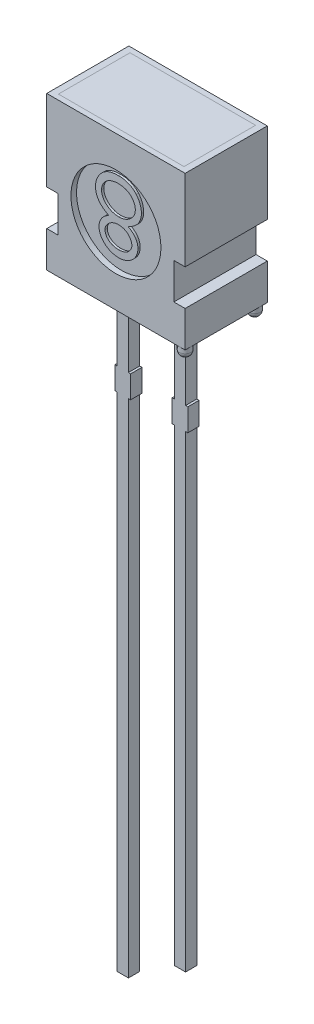
from build123d import *

# Parameters (mm, degrees)
EXTRUDE1_DEPTH     = 1.825
EXTRUDE2_DEPTH     = 0.25
SKETCH2_W          = 5.58
SKETCH2_H          = 3.18
CUT_EXTRUDE1_DEPTH = 6.8
CUT_EXTRUDE1_DRAFT = -4
SKETCH2_5_W        = 5.58
SKETCH2_5_H        = 3.18
EXTRUDE4_DEPTH     = 6.8
EXTRUDE4_DRAFT     = -4
SKETCH3_R          = 0.25
EXTRUDE5_DEPTH     = 0.5
EXTRUDE5_2_DEPTH   = 0.5
EXTRUDE5_3_DEPTH   = 0.5
FILLET1_R          = 0.25
FILLET2_R          = 0.25
FILLET3_R          = 0.25
SKETCH4_R          = 2
CUT_EXTRUDE2_DEPTH = 0.25
EXTRUDE6_DEPTH     = 0.1
SKETCH6_W          = 0.025316456
SKETCH6_H          = 0.026582278
CUT_EXTRUDE3_DEPTH = 0.01


with BuildPart() as part:
    # Sketch1 → Extrude1 (new body, symmetric)
    with BuildSketch(Plane.XY):
        Polygon((3.075, 3.4), (-3.075, 3.4), (-3.075, -0.2), (-2.575, -0.2), (-2.575, -1.8), (-3.075, -1.8), (-3.075, -3.4), (-1.52, -3.4), (-1.02, -3.4), (1.02, -3.4), (1.52, -3.4), (3.075, -3.4), (3.075, -1.8), (2.575, -1.8), (2.575, -0.2), (3.075, -0.2), align=None)
    extrude(amount=EXTRUDE1_DEPTH, both=True)

    # Sketch1_3 → Extrude2 (add, symmetric)
    with BuildSketch(Plane.XY):
        Polygon((-1.02, -3.4), (-1.52, -3.4), (-1.52, -7.1), (-1.62, -7.1), (-1.62, -8.1), (-1.52, -8.1), (-1.52, -30.4), (-1.02, -30.4), (-1.02, -8.1), (-0.92, -8.1), (-0.92, -7.1), (-1.02, -7.1), align=None)
        Polygon((1.52, -7.1), (1.52, -3.4), (1.02, -3.4), (1.02, -7.1), (0.92, -7.1), (0.92, -8.1), (1.02, -8.1), (1.02, -28.9), (1.52, -28.9), (1.52, -8.1), (1.62, -8.1), (1.62, -7.1), align=None)
    extrude(amount=EXTRUDE2_DEPTH, both=True)


with BuildPart() as cut_extrude1_tool:
    # Sketch2 → Cut-Extrude1 (with draft: the straight prism first)
    with BuildSketch(Plane(origin=(0, 3.4, 0), x_dir=(-1, 0, 0), z_dir=(0, 1, 0))):
        Rectangle(SKETCH2_W, SKETCH2_H)
    extrude(amount=-CUT_EXTRUDE1_DEPTH)
    # Cut-Extrude1: the draft: its side faces are tilted about the plane it starts from
    cut_extrude1_sides = [cut_extrude1_tool.faces().sort_by_distance(p)[0] for p in [
        (-2.79, 0, 0),
        (0, 0, 1.59),
        (2.79, 0, 0),
        (0, 0, -1.59),
    ]]
    draft(cut_extrude1_sides, Plane(origin=(0, 3.4, 0), x_dir=(-1, 0, 0), z_dir=(0, 1, 0)), CUT_EXTRUDE1_DRAFT)


with BuildPart() as part_1:
    add(part.part)

    # Cut-Extrude1: cut by cut_extrude1_tool
    add(cut_extrude1_tool.part, mode=Mode.SUBTRACT)

    # Sketch4 → Cut-Extrude2 (cut)
    with BuildSketch(Plane.XY.offset(1.825)):
        Circle(SKETCH4_R)
    extrude(amount=-CUT_EXTRUDE2_DEPTH, mode=Mode.SUBTRACT)

    # Sketch6 → Cut-Extrude3 (cut)
    with BuildSketch(Plane.XZ.offset(3.4)):
        Polygon((-0.609025376, -1.458987967), (-0.632482654, -1.533671511), (-0.657225534, -1.533671511), (-0.673641673, -1.483335277), (-0.689167781, -1.533671511), (-0.714899584, -1.533671511), (-0.7381393, -1.458987967), (-0.712961293, -1.458987967), (-0.699966831, -1.510471353), (-0.683550692, -1.458987967), (-0.662051483, -1.458987967), (-0.645734236, -1.510471353), (-0.632917781, -1.458987967), align=None)
        Polygon((-0.47484816, -1.458987967), (-0.498305439, -1.533671511), (-0.523048319, -1.533671511), (-0.539464458, -1.483335277), (-0.554990565, -1.533671511), (-0.580722369, -1.533671511), (-0.603962084, -1.458987967), (-0.578784078, -1.458987967), (-0.565789616, -1.510471353), (-0.549373477, -1.458987967), (-0.527874268, -1.458987967), (-0.511557021, -1.510471353), (-0.498740565, -1.458987967), align=None)
        Polygon((-0.340670945, -1.458987967), (-0.364128224, -1.533671511), (-0.388871103, -1.533671511), (-0.405287243, -1.483335277), (-0.42081335, -1.533671511), (-0.446545154, -1.533671511), (-0.469784869, -1.458987967), (-0.444606863, -1.458987967), (-0.431612401, -1.510471353), (-0.415196262, -1.458987967), (-0.393697053, -1.458987967), (-0.377379806, -1.510471353), (-0.36456335, -1.458987967), align=None)
        with Locations((-0.312822844, -1.520380372)):
            Rectangle(SKETCH6_W, SKETCH6_H)
        with BuildLine():
            add(Edge.make_bspline(
                [(-0.196367148, -1.502500625), (-0.196403637, -1.503722767), (-0.196475289, -1.506122645), (-0.197085006, -1.509630223), (-0.198078493, -1.512954928), (-0.19945261, -1.516117589), (-0.201241413, -1.519096207), (-0.203451003, -1.521876484), (-0.206015416, -1.524511284), (-0.208981626, -1.526917415), (-0.212261736, -1.529121791), (-0.215859311, -1.53101879), (-0.219738016, -1.532615273), (-0.223886602, -1.533953825), (-0.228333041, -1.534942405), (-0.23305057, -1.535666351), (-0.238043989, -1.53613968), (-0.241467567, -1.536181647), (-0.243222369, -1.536203157)],
                knots=[0, 0, 0, 0, 0.907352243, 1.781736951, 2.63548328, 3.47985091, 4.336556021, 5.208523475, 6.112432747, 7.062451073, 8.040435374, 9.043840564, 10.077958095, 11.152835584, 12.277940427, 13.457536469, 14.696825396, 16, 16, 16, 16], degree=3))
            add(Edge.make_bspline(
                [(-0.243222369, -1.536203157), (-0.245240625, -1.536179085), (-0.249149807, -1.536132461), (-0.254813332, -1.535703861), (-0.260081369, -1.535057722), (-0.264977084, -1.53409118), (-0.269581683, -1.532890415), (-0.274014951, -1.531599124), (-0.278296263, -1.530134708), (-0.281069352, -1.52903455), (-0.282443097, -1.528489549)],
                knots=[0, 0, 0, 0, 1.203215828, 2.33052265, 3.384689099, 4.366106119, 5.303329643, 6.221311756, 7.118865988, 8, 8, 8, 8], degree=3))
            Line((-0.282443097, -1.528489549), (-0.282443097, -1.504557587))
            Line((-0.282443097, -1.504557587), (-0.279594996, -1.504557587))
            add(Edge.make_bspline(
                [(-0.279594996, -1.504557587), (-0.278229682, -1.505639042), (-0.275507069, -1.507795603), (-0.271073836, -1.510558208), (-0.26642619, -1.512960371), (-0.261580719, -1.514934373), (-0.256683875, -1.516520697), (-0.251808497, -1.517614225), (-0.24704291, -1.518361574), (-0.24388434, -1.51844208), (-0.242332338, -1.518481638)],
                knots=[0, 0, 0, 0, 1.030622468, 2.055194264, 3.087043286, 4.125157485, 5.149848264, 6.130935704, 7.081611712, 8, 8, 8, 8], degree=3))
            add(Edge.make_bspline(
                [(-0.242332338, -1.518481638), (-0.241903561, -1.518480714), (-0.240985585, -1.518478737), (-0.239524058, -1.51835101), (-0.237872247, -1.518255433), (-0.236099738, -1.518048249), (-0.234303012, -1.517826388), (-0.232640611, -1.517451463), (-0.231131016, -1.517086596), (-0.230224495, -1.516718599), (-0.229792781, -1.516543347)],
                knots=[0, 0, 0, 0, 0.806402781, 1.726445712, 2.758724871, 3.919014682, 5.083870887, 6.16165551, 7.124521387, 8, 8, 8, 8], degree=3))
            add(Edge.make_bspline(
                [(-0.229792781, -1.516543347), (-0.229313218, -1.516315205), (-0.228370774, -1.515866858), (-0.227077175, -1.515056539), (-0.225909495, -1.514173074), (-0.224852123, -1.513208143), (-0.223977843, -1.512042393), (-0.223353976, -1.510633721), (-0.223009083, -1.508984703), (-0.222970059, -1.5078095), (-0.222949426, -1.507188125)],
                knots=[0, 0, 0, 0, 1.024747072, 2.013846092, 2.940605744, 3.850156746, 4.769278501, 5.73222711, 6.800942666, 8, 8, 8, 8], degree=3))
            add(Edge.make_bspline(
                [(-0.222949426, -1.507188125), (-0.222981271, -1.506642488), (-0.223043887, -1.505569604), (-0.22362108, -1.50403449), (-0.224530518, -1.502625321), (-0.225812108, -1.501356547), (-0.227405284, -1.500207013), (-0.229347667, -1.499224708), (-0.231597788, -1.49835152), (-0.233241859, -1.497933542), (-0.234104489, -1.497714233)],
                knots=[0, 0, 0, 0, 0.82557554, 1.623324704, 2.456147571, 3.35491006, 4.343819762, 5.427079081, 6.650009487, 8, 8, 8, 8], degree=3))
            add(Edge.make_bspline(
                [(-0.234104489, -1.497714233), (-0.236073116, -1.497265993), (-0.240112126, -1.496346342), (-0.24626195, -1.495207588), (-0.252390301, -1.493932728), (-0.256343067, -1.492726085), (-0.258273793, -1.492136701)],
                knots=[0, 0, 0, 0, 0.976100998, 2.002656142, 3.024398856, 4, 4, 4, 4], degree=3))
            add(Edge.make_bspline(
                [(-0.258273793, -1.492136701), (-0.259312311, -1.491783711), (-0.261333884, -1.491096583), (-0.264225396, -1.489934923), (-0.266886623, -1.488665094), (-0.269326337, -1.487309539), (-0.271527026, -1.485836999), (-0.273521293, -1.484295621), (-0.27528441, -1.482655581), (-0.276831215, -1.480915815), (-0.278156117, -1.479065112), (-0.279308502, -1.477119915), (-0.280291122, -1.475064495), (-0.28106916, -1.472894272), (-0.2816938, -1.470620617), (-0.282112782, -1.468242905), (-0.282411799, -1.465759776), (-0.282432522, -1.464065391), (-0.282443097, -1.463200784)],
                knots=[0, 0, 0, 0, 1.287047841, 2.5053592, 3.654260482, 4.74538952, 5.777514103, 6.75871007, 7.700244599, 8.599107454, 9.48590269, 10.366941872, 11.24940663, 12.154970331, 13.068988358, 14.012872203, 14.986013017, 16, 16, 16, 16], degree=3))
            add(Edge.make_bspline(
                [(-0.282443097, -1.463200784), (-0.282405795, -1.462044639), (-0.282332386, -1.459769367), (-0.281730957, -1.456440322), (-0.280704367, -1.453291586), (-0.279318304, -1.450288123), (-0.277489676, -1.447475037), (-0.275304881, -1.444796489), (-0.272680833, -1.442324898), (-0.269703712, -1.440024564), (-0.266416328, -1.437945165), (-0.262877344, -1.436114609), (-0.259108055, -1.434577958), (-0.255122508, -1.433304064), (-0.25090404, -1.432349393), (-0.246466807, -1.431630461), (-0.241793018, -1.431217279), (-0.238601597, -1.431166029), (-0.236972369, -1.431139866)],
                knots=[0, 0, 0, 0, 0.894990994, 1.761326291, 2.609044902, 3.454222546, 4.315366365, 5.200560057, 6.125081389, 7.100429509, 8.110379559, 9.133447974, 10.182136699, 11.259192205, 12.370181258, 13.528580438, 14.738335141, 16, 16, 16, 16], degree=3))
            add(Edge.make_bspline(
                [(-0.236972369, -1.431139866), (-0.235303675, -1.431162019), (-0.231969117, -1.431206287), (-0.226987777, -1.431584844), (-0.222033349, -1.432137155), (-0.217170924, -1.432986396), (-0.212478761, -1.433954628), (-0.208059647, -1.435053901), (-0.203980094, -1.436291407), (-0.201406441, -1.437245809), (-0.200164616, -1.437706322)],
                knots=[0, 0, 0, 0, 1.065407564, 2.129008667, 3.188544425, 4.247469455, 5.279542408, 6.247502114, 7.154394069, 8, 8, 8, 8], degree=3))
            Line((-0.200164616, -1.437706322), (-0.200164616, -1.46025379))
            Line((-0.200164616, -1.46025379), (-0.202992939, -1.46025379))
            add(Edge.make_bspline(
                [(-0.202992939, -1.46025379), (-0.204066442, -1.459454502), (-0.20625722, -1.457823337), (-0.209906824, -1.455721601), (-0.213874444, -1.45378151), (-0.21815607, -1.452089853), (-0.222615851, -1.450631846), (-0.227198609, -1.449612288), (-0.231824825, -1.44897058), (-0.234926529, -1.448897791), (-0.236477907, -1.448861385)],
                knots=[0, 0, 0, 0, 0.892265782, 1.820912499, 2.804518821, 3.836954028, 4.889985052, 5.931488012, 6.965393252, 8, 8, 8, 8], degree=3))
            add(Edge.make_bspline(
                [(-0.236477907, -1.448861385), (-0.237573512, -1.448883287), (-0.239771156, -1.448927221), (-0.243040347, -1.449312107), (-0.246280825, -1.44995096), (-0.248315507, -1.450767011), (-0.24933392, -1.451175467)],
                knots=[0, 0, 0, 0, 0.999122297, 2.004111588, 3.001004448, 4, 4, 4, 4], degree=3))
            add(Edge.make_bspline(
                [(-0.24933392, -1.451175467), (-0.249767649, -1.451376646), (-0.250634819, -1.45177887), (-0.251842361, -1.452558495), (-0.252963333, -1.453474839), (-0.253958916, -1.454527596), (-0.25480335, -1.45569595), (-0.255422376, -1.456963532), (-0.255796869, -1.458327414), (-0.255839216, -1.459262513), (-0.255860819, -1.459739549)],
                knots=[0, 0, 0, 0, 1.004925302, 2.009180302, 3.014392739, 4.04465309, 5.049195417, 6.035570224, 6.99785458, 8, 8, 8, 8], degree=3))
            add(Edge.make_bspline(
                [(-0.255860819, -1.459739549), (-0.25582638, -1.460377715), (-0.255760572, -1.46159719), (-0.255153988, -1.463312986), (-0.254169155, -1.46479142), (-0.25300855, -1.46578634), (-0.25189142, -1.466483778), (-0.250855761, -1.466994289), (-0.249646533, -1.467477648), (-0.248275286, -1.467975116), (-0.246738959, -1.468466304), (-0.245030402, -1.46894185), (-0.243147685, -1.469391146), (-0.24183181, -1.469677337), (-0.241145629, -1.469826575)],
                knots=[0, 0, 0, 0, 1.173816843, 2.243057204, 3.312297565, 4.415174738, 5.03266065, 5.73970059, 6.541434878, 7.433956553, 8.430083051, 9.515931566, 10.70464786, 12, 12, 12, 12], degree=3))
            add(Edge.make_bspline(
                [(-0.241145629, -1.469826575), (-0.239312706, -1.470202019), (-0.23571774, -1.47093839), (-0.230318516, -1.472050756), (-0.224813528, -1.473316115), (-0.221142376, -1.474468111), (-0.219231072, -1.475067872)],
                knots=[0, 0, 0, 0, 0.995749986, 1.952994291, 2.934271555, 4, 4, 4, 4], degree=3))
            add(Edge.make_bspline(
                [(-0.219231072, -1.475067872), (-0.218284583, -1.475387231), (-0.216433099, -1.476011949), (-0.213791552, -1.477096633), (-0.211342499, -1.478278722), (-0.209064228, -1.479501208), (-0.207002147, -1.480864425), (-0.205108923, -1.482279072), (-0.203425905, -1.483807181), (-0.201927955, -1.485420039), (-0.200609554, -1.487130471), (-0.19947459, -1.488968574), (-0.198511444, -1.490923103), (-0.197703313, -1.492996175), (-0.197125297, -1.495203243), (-0.196691239, -1.497529543), (-0.196400417, -1.499974859), (-0.196378361, -1.501649305), (-0.196367148, -1.502500625)],
                knots=[0, 0, 0, 0, 1.237386967, 2.420528625, 3.534815053, 4.605870898, 5.620827102, 6.594482803, 7.531295079, 8.432978826, 9.318460435, 10.202471551, 11.10474705, 12.014900263, 12.954095338, 13.926516828, 14.945802342, 16, 16, 16, 16], degree=3))
        make_face()
        with BuildLine():
            Line((-0.103962084, -1.533671511), (-0.128012717, -1.533671511))
            Line((-0.128012717, -1.533671511), (-0.128012717, -1.525839233))
            add(Edge.make_bspline(
                [(-0.128012717, -1.525839233), (-0.129105973, -1.5266479), (-0.131213753, -1.528206999), (-0.134387492, -1.530285763), (-0.137416213, -1.532068925), (-0.140337814, -1.533611078), (-0.143353169, -1.534801925), (-0.146580672, -1.535623781), (-0.150082936, -1.536124901), (-0.15250991, -1.536176492), (-0.1537643, -1.536203157)],
                knots=[0, 0, 0, 0, 1.150906677, 2.218931226, 3.20955724, 4.125565256, 5.012676028, 5.946647191, 6.938718366, 8, 8, 8, 8], degree=3))
            add(Edge.make_bspline(
                [(-0.1537643, -1.536203157), (-0.154780645, -1.536180428), (-0.156759763, -1.536136168), (-0.159637092, -1.53579143), (-0.162344404, -1.535253284), (-0.164860554, -1.534447428), (-0.167225899, -1.533473311), (-0.169377418, -1.532214224), (-0.171365106, -1.530754887), (-0.173168484, -1.529077951), (-0.174759103, -1.527156989), (-0.176146154, -1.525034238), (-0.177321966, -1.5226996), (-0.178263604, -1.520148233), (-0.179018537, -1.517389789), (-0.179542515, -1.514410582), (-0.179863095, -1.511223443), (-0.179895036, -1.509028314), (-0.179911451, -1.507900151)],
                knots=[0, 0, 0, 0, 1.108935798, 2.159418225, 3.158520219, 4.116592843, 5.038730546, 5.944611115, 6.829677354, 7.725673622, 8.624842385, 9.544872214, 10.487719724, 11.471363217, 12.50822837, 13.604887271, 14.769056852, 16, 16, 16, 16], degree=3))
            Line((-0.179911451, -1.507900151), (-0.179911451, -1.458987967))
            Line((-0.179911451, -1.458987967), (-0.155860819, -1.458987967))
            Line((-0.155860819, -1.458987967), (-0.155860819, -1.496567081))
            add(Edge.make_bspline(
                [(-0.155860819, -1.496567081), (-0.155859183, -1.497483552), (-0.155856052, -1.499237768), (-0.155773714, -1.501743574), (-0.155652813, -1.504011747), (-0.155514108, -1.506053775), (-0.155261092, -1.507900526), (-0.154883383, -1.509566687), (-0.154412557, -1.511086289), (-0.153948238, -1.511992991), (-0.153724743, -1.512429423)],
                knots=[0, 0, 0, 0, 1.361401701, 2.605856924, 3.723918663, 4.735739235, 5.645738665, 6.489217889, 7.27279937, 8, 8, 8, 8], degree=3))
            add(Edge.make_bspline(
                [(-0.153724743, -1.512429423), (-0.153494703, -1.512828071), (-0.153042464, -1.513611778), (-0.152122653, -1.514618926), (-0.15104667, -1.515455832), (-0.149777031, -1.516128476), (-0.14828395, -1.51661218), (-0.14655195, -1.516958927), (-0.144565934, -1.51717275), (-0.143157015, -1.517200912), (-0.142411451, -1.517215815)],
                knots=[0, 0, 0, 0, 0.849057291, 1.669173542, 2.503217716, 3.359509317, 4.311793648, 5.394940091, 6.621469141, 8, 8, 8, 8], degree=3))
            add(Edge.make_bspline(
                [(-0.142411451, -1.517215815), (-0.141870187, -1.517198358), (-0.140757309, -1.517162464), (-0.139052097, -1.516932536), (-0.137263069, -1.516570879), (-0.134748872, -1.515911856), (-0.131572727, -1.514732678), (-0.129208588, -1.513373876), (-0.128012717, -1.512686543)],
                knots=[0, 0, 0, 0, 0.638164724, 1.312110757, 2.025558264, 2.789159289, 4.375836335, 6, 6, 6, 6], degree=3))
            Line((-0.128012717, -1.512686543), (-0.128012717, -1.458987967))
            Line((-0.128012717, -1.458987967), (-0.103962084, -1.458987967))
            Line((-0.103962084, -1.458987967), (-0.103962084, -1.533671511))
        make_face()
        with BuildLine():
            Line((-0.00649373, -1.533671511), (-0.030544363, -1.533671511))
            Line((-0.030544363, -1.533671511), (-0.030544363, -1.496092398))
            add(Edge.make_bspline(
                [(-0.030544363, -1.496092398), (-0.030564687, -1.494561924), (-0.030605222, -1.491509512), (-0.030938802, -1.487752736), (-0.031272511, -1.484904946), (-0.031649334, -1.483068879), (-0.032079521, -1.481520543), (-0.032491966, -1.480634805), (-0.032680439, -1.480230056)],
                knots=[0, 0, 0, 0, 1.709235885, 3.408940626, 4.211008593, 4.910095588, 5.501954032, 6, 6, 6, 6], degree=3))
            add(Edge.make_bspline(
                [(-0.032680439, -1.480230056), (-0.032924867, -1.479831933), (-0.033404104, -1.479051358), (-0.034341919, -1.478039336), (-0.035438568, -1.477203122), (-0.036717292, -1.476538173), (-0.038201945, -1.476052275), (-0.039914619, -1.475665616), (-0.04190059, -1.475497055), (-0.043307958, -1.475462146), (-0.044053065, -1.475443663)],
                knots=[0, 0, 0, 0, 0.860145871, 1.686437142, 2.528070002, 3.393017362, 4.331453407, 5.402595683, 6.624848233, 8, 8, 8, 8], degree=3))
            add(Edge.make_bspline(
                [(-0.044053065, -1.475443663), (-0.045184955, -1.475500244), (-0.047496188, -1.475615777), (-0.050357479, -1.476329368), (-0.052684355, -1.477141666), (-0.054529976, -1.477915902), (-0.056446505, -1.478870528), (-0.057729929, -1.479597602), (-0.058392464, -1.479972935)],
                knots=[0, 0, 0, 0, 1.338419466, 2.732951426, 3.468143565, 4.254837763, 5.099104234, 6, 6, 6, 6], degree=3))
            Line((-0.058392464, -1.479972935), (-0.058392464, -1.533671511))
            Line((-0.058392464, -1.533671511), (-0.082443097, -1.533671511))
            Line((-0.082443097, -1.533671511), (-0.082443097, -1.458987967))
            Line((-0.082443097, -1.458987967), (-0.058392464, -1.458987967))
            Line((-0.058392464, -1.458987967), (-0.058392464, -1.466820246))
            add(Edge.make_bspline(
                [(-0.058392464, -1.466820246), (-0.057335227, -1.466013808), (-0.055277251, -1.464444029), (-0.052100499, -1.462410619), (-0.049029787, -1.460600763), (-0.045975265, -1.459088628), (-0.042850767, -1.457890028), (-0.039583136, -1.457074425), (-0.036166424, -1.456531477), (-0.033829751, -1.456481665), (-0.032640882, -1.456456322)],
                knots=[0, 0, 0, 0, 1.126064518, 2.191951536, 3.19307265, 4.144813015, 5.076393104, 6.021983703, 6.993610568, 8, 8, 8, 8], degree=3))
            add(Edge.make_bspline(
                [(-0.032640882, -1.456456322), (-0.03164461, -1.456481711), (-0.029699711, -1.456531274), (-0.026864951, -1.456840984), (-0.02419353, -1.457391648), (-0.021701255, -1.458189478), (-0.019358639, -1.459175091), (-0.017196682, -1.460406601), (-0.015204656, -1.461865041), (-0.013376087, -1.463525982), (-0.011745906, -1.46541594), (-0.01032642, -1.467532313), (-0.009154997, -1.469881042), (-0.008146165, -1.472428178), (-0.00741194, -1.475205949), (-0.006885489, -1.478196715), (-0.006535059, -1.481401897), (-0.006507782, -1.483617797), (-0.00649373, -1.484759328)],
                knots=[0, 0, 0, 0, 1.088441561, 2.124831547, 3.110816719, 4.062969431, 4.979391633, 5.88258537, 6.774334107, 7.671621258, 8.575503974, 9.49441354, 10.447872957, 11.437639084, 12.482478955, 13.580222388, 14.753440527, 16, 16, 16, 16], degree=3))
            Line((-0.00649373, -1.484759328), (-0.00649373, -1.533671511))
        make_face()
        Polygon((0.088442979, -1.533671511), (0.01629108, -1.533671511), (0.01629108, -1.433671511), (0.041607536, -1.433671511), (0.041607536, -1.51468417), (0.088442979, -1.51468417), align=None)
        Polygon((0.175784751, -1.533671511), (0.103632852, -1.533671511), (0.103632852, -1.433671511), (0.175784751, -1.433671511), (0.175784751, -1.452658853), (0.128949308, -1.452658853), (0.128949308, -1.470380372), (0.171987283, -1.470380372), (0.171987283, -1.489367714), (0.128949308, -1.489367714), (0.128949308, -1.51468417), (0.175784751, -1.51468417), align=None)
        with BuildLine():
            add(Edge.make_bspline(
                [(0.292240447, -1.483770404), (0.292221132, -1.484918093), (0.29218288, -1.487190979), (0.291887689, -1.490555785), (0.291361663, -1.493821461), (0.290682482, -1.497005709), (0.289759976, -1.500084637), (0.288678262, -1.503092214), (0.287368616, -1.505997708), (0.285863764, -1.508799142), (0.284214292, -1.511471245), (0.282439543, -1.513991454), (0.280593763, -1.516374672), (0.278604451, -1.518569566), (0.276525269, -1.520611585), (0.274349741, -1.522502399), (0.272044676, -1.52420583), (0.270437514, -1.525228714), (0.269633643, -1.525740341)],
                knots=[0, 0, 0, 0, 1.105570398, 2.18947457, 3.250358341, 4.290584537, 5.323553275, 6.344225964, 7.367641686, 8.3905646, 9.405808457, 10.390761353, 11.358902336, 12.307789878, 13.241960776, 14.165076779, 15.082208636, 16, 16, 16, 16], degree=3))
            add(Edge.make_bspline(
                [(0.269633643, -1.525740341), (0.268394423, -1.52645251), (0.265909658, -1.527880484), (0.261925711, -1.529548615), (0.257794593, -1.530956571), (0.253436039, -1.532004761), (0.24878969, -1.532733494), (0.243795033, -1.533296544), (0.238393906, -1.533596909), (0.234659023, -1.533646077), (0.232726998, -1.533671511)],
                knots=[0, 0, 0, 0, 0.896298978, 1.797171328, 2.70531317, 3.633678302, 4.606491125, 5.655688921, 6.787306437, 8, 8, 8, 8], degree=3))
            Line((0.232726998, -1.533671511), (0.197303738, -1.533671511))
            Line((0.197303738, -1.533671511), (0.197303738, -1.433671511))
            Line((0.197303738, -1.433671511), (0.2337357, -1.433671511))
            add(Edge.make_bspline(
                [(0.2337357, -1.433671511), (0.235714424, -1.433688207), (0.239531137, -1.43372041), (0.245041555, -1.434136378), (0.250139935, -1.434735898), (0.254824514, -1.43566259), (0.25913292, -1.436771241), (0.263063942, -1.438134277), (0.266675831, -1.439632549), (0.268854659, -1.440906297), (0.269910542, -1.441523568)],
                knots=[0, 0, 0, 0, 1.267192274, 2.444256634, 3.537982003, 4.553396635, 5.500903572, 6.385021601, 7.217363933, 8, 8, 8, 8], degree=3))
            add(Edge.make_bspline(
                [(0.269910542, -1.441523568), (0.270761496, -1.442060109), (0.27245362, -1.443127022), (0.274854835, -1.444908875), (0.277084262, -1.446864952), (0.279212766, -1.44891677), (0.28119258, -1.451119658), (0.283035793, -1.453458362), (0.284739559, -1.455936469), (0.286297715, -1.458545888), (0.2877178, -1.461276128), (0.288909879, -1.464148474), (0.289949242, -1.467131347), (0.290795324, -1.470230286), (0.291451654, -1.473447676), (0.291897738, -1.476785156), (0.29218117, -1.480238345), (0.292220522, -1.482583138), (0.292240447, -1.483770404)],
                knots=[0, 0, 0, 0, 0.964043478, 1.917004671, 2.862223898, 3.805158963, 4.749279098, 5.698713747, 6.657523689, 7.629652222, 8.610369353, 9.604453025, 10.607693792, 11.636365947, 12.681120053, 13.752669011, 14.862083412, 16, 16, 16, 16], degree=3))
        make_face()
        with BuildLine():
            add(Edge.make_bspline(
                [(0.265658169, -1.483612176), (0.265647698, -1.482807463), (0.265627159, -1.481228971), (0.265438836, -1.478912795), (0.265168248, -1.476686746), (0.264779115, -1.474543113), (0.264238682, -1.472492965), (0.263606501, -1.470531396), (0.26287941, -1.468652472), (0.26199848, -1.466874813), (0.261024656, -1.465166476), (0.259877212, -1.463580948), (0.258628861, -1.462068066), (0.257250578, -1.46064008), (0.255707637, -1.459334184), (0.254047535, -1.458104108), (0.252247177, -1.456975782), (0.250974189, -1.456315732), (0.250329846, -1.455981638)],
                knots=[0, 0, 0, 0, 1.152052275, 2.259818351, 3.325348653, 4.362224493, 5.376551665, 6.358740615, 7.312387502, 8.258104984, 9.197203025, 10.124507262, 11.056413058, 12.004389423, 12.961766972, 13.947352551, 14.961020569, 16, 16, 16, 16], degree=3))
            add(Edge.make_bspline(
                [(0.250329846, -1.455981638), (0.249654948, -1.455674926), (0.248317254, -1.455067001), (0.246246431, -1.454335809), (0.244157048, -1.453762973), (0.241955448, -1.453332115), (0.239485689, -1.453010184), (0.236560107, -1.452812926), (0.233104197, -1.452670756), (0.230617482, -1.452663005), (0.229285542, -1.452658853)],
                knots=[0, 0, 0, 0, 0.826967603, 1.639107464, 2.447640171, 3.242670507, 4.14065217, 5.225198036, 6.513753944, 8, 8, 8, 8], degree=3))
            Line((0.229285542, -1.452658853), (0.222620194, -1.452658853))
            Line((0.222620194, -1.452658853), (0.222620194, -1.51468417))
            Line((0.222620194, -1.51468417), (0.229285542, -1.51468417))
            add(Edge.make_bspline(
                [(0.229285542, -1.51468417), (0.23004375, -1.514679424), (0.231507516, -1.514670262), (0.233623754, -1.514627148), (0.23558957, -1.514580434), (0.237394375, -1.514463397), (0.239046718, -1.514392897), (0.240532866, -1.514209226), (0.241869815, -1.514074751), (0.243442296, -1.513797029), (0.245297483, -1.513391053), (0.247464272, -1.512707896), (0.249604971, -1.511858321), (0.250993522, -1.511173242), (0.251694561, -1.510827366)],
                knots=[0, 0, 0, 0, 1.186805873, 2.291202465, 3.313317863, 4.264127762, 5.122212376, 5.900577546, 6.607154111, 7.224697658, 8.398873738, 9.57716935, 10.776782771, 12, 12, 12, 12], degree=3))
            add(Edge.make_bspline(
                [(0.251694561, -1.510827366), (0.252279675, -1.510485848), (0.253433596, -1.50981233), (0.255057135, -1.50867828), (0.256564725, -1.50747047), (0.257961203, -1.506182329), (0.259222789, -1.504792944), (0.260378876, -1.503333478), (0.261384263, -1.501773157), (0.262623517, -1.49958433), (0.263870607, -1.496559573), (0.264903007, -1.492586819), (0.265542154, -1.488227907), (0.265618507, -1.485190167), (0.265658169, -1.483612176)],
                knots=[0, 0, 0, 0, 0.755237594, 1.489427721, 2.205882609, 2.908165467, 3.605466573, 4.296695275, 4.981837198, 5.673065901, 7.099889822, 8.61390339, 10.241051878, 12, 12, 12, 12], degree=3))
        make_face(mode=Mode.SUBTRACT)
        with Locations((0.323886017, -1.520380372)):
            Rectangle(SKETCH6_W, SKETCH6_H)
        with BuildLine():
            add(Edge.make_bspline(
                [(0.398530004, -1.536203157), (0.396939888, -1.536181354), (0.393818744, -1.536138558), (0.389247456, -1.535661529), (0.38488209, -1.534944233), (0.380736466, -1.533921914), (0.376825923, -1.532581395), (0.373170973, -1.530911388), (0.369754302, -1.528944193), (0.367692382, -1.527359296), (0.366666871, -1.526571037)],
                knots=[0, 0, 0, 0, 1.123701398, 2.205645569, 3.245398653, 4.249180969, 5.220497262, 6.163202923, 7.086456062, 8, 8, 8, 8], degree=3))
            add(Edge.make_bspline(
                [(0.366666871, -1.526571037), (0.365715237, -1.525716204), (0.363815647, -1.524009843), (0.36134802, -1.5210393), (0.359229944, -1.517750327), (0.357417688, -1.514158674), (0.355985737, -1.510238789), (0.354993202, -1.505988894), (0.354365598, -1.501431565), (0.354299646, -1.49828336), (0.354265764, -1.496665973)],
                knots=[0, 0, 0, 0, 0.916342154, 1.829140869, 2.758848968, 3.716597128, 4.708179637, 5.743612459, 6.840783343, 8, 8, 8, 8], degree=3))
            add(Edge.make_bspline(
                [(0.354265764, -1.496665973), (0.354304524, -1.494962746), (0.354379647, -1.491661666), (0.355043407, -1.486889479), (0.356113019, -1.482471798), (0.357650577, -1.47841989), (0.359581019, -1.474726698), (0.361845512, -1.471354864), (0.364466038, -1.468311939), (0.366473176, -1.4665665), (0.367477789, -1.465692872)],
                knots=[0, 0, 0, 0, 1.171797512, 2.271099083, 3.308930235, 4.294129479, 5.24602549, 6.17106565, 7.084581485, 8, 8, 8, 8], degree=3))
            add(Edge.make_bspline(
                [(0.367477789, -1.465692872), (0.368503573, -1.464924093), (0.370567531, -1.46337725), (0.373967071, -1.461482438), (0.377579283, -1.459877921), (0.3814104, -1.458632035), (0.385390918, -1.457683498), (0.389456459, -1.456956526), (0.393602826, -1.456536501), (0.396393011, -1.456483177), (0.3977982, -1.456456322)],
                knots=[0, 0, 0, 0, 0.952097844, 1.915695341, 2.885641886, 3.886921822, 4.905719434, 5.925883802, 6.95543633, 8, 8, 8, 8], degree=3))
            add(Edge.make_bspline(
                [(0.3977982, -1.456456322), (0.399044927, -1.456473285), (0.401496414, -1.456506642), (0.405097348, -1.456829299), (0.408545932, -1.457359463), (0.411843244, -1.458103057), (0.415016392, -1.458995856), (0.418075865, -1.460027137), (0.421040681, -1.461165078), (0.422941358, -1.462049293), (0.423886017, -1.462488758)],
                knots=[0, 0, 0, 0, 1.107671842, 2.178058178, 3.209662749, 4.206063564, 5.179815947, 6.137646632, 7.07438927, 8, 8, 8, 8], degree=3))
            Line((0.423886017, -1.462488758), (0.423886017, -1.4830386))
            Line((0.423886017, -1.4830386), (0.420543454, -1.4830386))
            add(Edge.make_bspline(
                [(0.420543454, -1.4830386), (0.420044685, -1.482620373), (0.41896275, -1.481713149), (0.417161397, -1.480312136), (0.415027887, -1.478761571), (0.413376679, -1.477875568), (0.412493612, -1.477401733)],
                knots=[0, 0, 0, 0, 0.792878214, 1.719922066, 2.780612869, 4, 4, 4, 4], degree=3))
            add(Edge.make_bspline(
                [(0.412493612, -1.477401733), (0.411565952, -1.476958864), (0.409658924, -1.476048441), (0.407098946, -1.475228898), (0.404909915, -1.474650361), (0.403098032, -1.474397551), (0.401164612, -1.474207203), (0.399829341, -1.474187808), (0.399143137, -1.474177841)],
                knots=[0, 0, 0, 0, 1.33256682, 2.739414054, 3.480190821, 4.267897792, 5.109861573, 6, 6, 6, 6], degree=3))
            add(Edge.make_bspline(
                [(0.399143137, -1.474177841), (0.398377589, -1.4741974), (0.396893991, -1.474235305), (0.394732389, -1.474512227), (0.392714313, -1.474990962), (0.390809904, -1.475629374), (0.389071158, -1.476525613), (0.387428628, -1.477537881), (0.385954152, -1.478792389), (0.384612205, -1.480210129), (0.383424721, -1.481800643), (0.382397969, -1.48352713), (0.381515243, -1.485385023), (0.380813349, -1.487382931), (0.380255839, -1.489512793), (0.379866274, -1.491775604), (0.379624495, -1.494175201), (0.379596553, -1.495821497), (0.379582219, -1.496665973)],
                knots=[0, 0, 0, 0, 1.087094245, 2.106738054, 3.087824582, 4.029427112, 4.95060567, 5.859714611, 6.763601524, 7.690850518, 8.627131371, 9.576106403, 10.539384251, 11.543302637, 12.578856349, 13.662518017, 14.800975475, 16, 16, 16, 16], degree=3))
            add(Edge.make_bspline(
                [(0.379582219, -1.496665973), (0.379596994, -1.49753013), (0.3796257, -1.499209142), (0.379859214, -1.501650753), (0.380275105, -1.503932185), (0.380846353, -1.506057504), (0.381570701, -1.508023523), (0.382475818, -1.509820919), (0.383512175, -1.511477727), (0.384756733, -1.512940339), (0.386120617, -1.51425666), (0.387635508, -1.515392795), (0.389294747, -1.51634094), (0.391076928, -1.517145403), (0.393009969, -1.517723801), (0.395066505, -1.518160493), (0.39725606, -1.518449049), (0.398766414, -1.518470612), (0.399538707, -1.518481638)],
                knots=[0, 0, 0, 0, 1.230336593, 2.390482092, 3.487897344, 4.52859895, 5.520747884, 6.465347575, 7.38981449, 8.296085817, 9.192433006, 10.084246191, 10.984321635, 11.908883871, 12.862027947, 13.850751296, 14.901019963, 16, 16, 16, 16], degree=3))
            add(Edge.make_bspline(
                [(0.399538707, -1.518481638), (0.400264549, -1.518473415), (0.401679552, -1.518457383), (0.403737974, -1.518241317), (0.405691891, -1.51796199), (0.407526438, -1.517520714), (0.409230687, -1.51698583), (0.41079634, -1.516415003), (0.412208947, -1.515810723), (0.413070281, -1.515343108), (0.413482536, -1.515119296)],
                knots=[0, 0, 0, 0, 1.200879421, 2.341068892, 3.423000803, 4.465923194, 5.460027553, 6.378409259, 7.223869634, 8, 8, 8, 8], degree=3))
            add(Edge.make_bspline(
                [(0.413482536, -1.515119296), (0.414190892, -1.51469161), (0.415552265, -1.513869651), (0.417377384, -1.512449191), (0.419021509, -1.511042751), (0.420045614, -1.510085984), (0.420543454, -1.509620879)],
                knots=[0, 0, 0, 0, 1.105932972, 2.12546697, 3.088749538, 4, 4, 4, 4], degree=3))
            Line((0.420543454, -1.509620879), (0.423886017, -1.509620879))
            Line((0.423886017, -1.509620879), (0.423886017, -1.530328948))
            add(Edge.make_bspline(
                [(0.423886017, -1.530328948), (0.42294064, -1.53076649), (0.421049659, -1.53164168), (0.418134882, -1.53279483), (0.415141639, -1.53376771), (0.41209041, -1.534660056), (0.408920778, -1.535358251), (0.405603428, -1.535847481), (0.402122124, -1.53614922), (0.399743708, -1.536184933), (0.398530004, -1.536203157)],
                knots=[0, 0, 0, 0, 0.952024047, 1.90427691, 2.862762905, 3.827874523, 4.80891974, 5.826446878, 6.890837857, 8, 8, 8, 8], degree=3))
        make_face()
        with BuildLine():
            add(Edge.make_bspline(
                [(0.51629108, -1.496369296), (0.51626616, -1.497874128), (0.516217585, -1.500807449), (0.515681377, -1.505080269), (0.514857914, -1.509110711), (0.51372459, -1.512911548), (0.512206736, -1.516454594), (0.510364322, -1.519750548), (0.508190731, -1.522802731), (0.505700413, -1.525592957), (0.502898927, -1.528091149), (0.499825161, -1.530287342), (0.496455295, -1.53209439), (0.492846549, -1.53362094), (0.488957242, -1.534777041), (0.484798147, -1.535594991), (0.480380638, -1.536129323), (0.477342272, -1.536178135), (0.475784751, -1.536203157)],
                knots=[0, 0, 0, 0, 1.120122129, 2.18341868, 3.201215738, 4.181270334, 5.131540819, 6.065757527, 6.988093576, 7.916512302, 8.844931028, 9.778115023, 10.722851943, 11.686686084, 12.691660064, 13.738321946, 14.84062285, 16, 16, 16, 16], degree=3))
            add(Edge.make_bspline(
                [(0.475784751, -1.536203157), (0.474227203, -1.536178217), (0.471188784, -1.536129565), (0.46677165, -1.535594095), (0.462617431, -1.534781378), (0.458732779, -1.533612143), (0.455118468, -1.532100052), (0.451744641, -1.530286611), (0.448670459, -1.528091358), (0.445869257, -1.525592847), (0.44337822, -1.522802962), (0.441207215, -1.519749733), (0.439356276, -1.51645994), (0.437875883, -1.512902665), (0.436703352, -1.509115457), (0.435890572, -1.505079459), (0.435351255, -1.500807668), (0.435303117, -1.497874202), (0.435278422, -1.496369296)],
                knots=[0, 0, 0, 0, 1.159424321, 2.261770074, 3.308474541, 4.308788811, 5.277191138, 6.221966496, 7.15518846, 8.08364496, 9.01210146, 9.934475036, 10.868729753, 11.817121636, 12.798654016, 13.816492484, 14.879832297, 16, 16, 16, 16], degree=3))
            add(Edge.make_bspline(
                [(0.435278422, -1.496369296), (0.435303545, -1.494857873), (0.43535263, -1.491904862), (0.435888, -1.487605989), (0.436706017, -1.483545339), (0.437866049, -1.479737026), (0.439382322, -1.476185426), (0.441223347, -1.472883321), (0.443419815, -1.469836746), (0.445929314, -1.467046995), (0.448741107, -1.464550613), (0.451835039, -1.462377708), (0.455186958, -1.460541051), (0.458794158, -1.459019217), (0.462680713, -1.457884652), (0.466817656, -1.457067074), (0.471215049, -1.456529001), (0.474233788, -1.456480989), (0.475784751, -1.456456322)],
                knots=[0, 0, 0, 0, 1.124034801, 2.196132384, 3.217834281, 4.203147447, 5.152578239, 6.085969439, 7.010345409, 7.941219594, 8.872481455, 9.802010446, 10.748267785, 11.711250247, 12.709230373, 13.754967386, 14.846549946, 16, 16, 16, 16], degree=3))
            add(Edge.make_bspline(
                [(0.475784751, -1.456456322), (0.477355495, -1.456481034), (0.480413671, -1.456529147), (0.484857, -1.457065486), (0.48903113, -1.457878012), (0.492928739, -1.459046082), (0.496552747, -1.460549352), (0.499899923, -1.462404298), (0.502984882, -1.464578648), (0.505753144, -1.467108477), (0.508236903, -1.469903431), (0.510399259, -1.472961111), (0.512234736, -1.476268687), (0.513710478, -1.479830562), (0.514884681, -1.483623194), (0.515705093, -1.487657621), (0.516211244, -1.491932527), (0.516264006, -1.49486467), (0.51629108, -1.496369296)],
                knots=[0, 0, 0, 0, 1.167473013, 2.273023816, 3.322954552, 4.326451713, 5.293391623, 6.234801871, 7.166614545, 8.093305908, 9.017100806, 9.942078766, 10.872536262, 11.824015763, 12.804065898, 13.820367293, 14.881523901, 16, 16, 16, 16], degree=3))
        make_face()
        with BuildLine():
            add(Edge.make_bspline(
                [(0.486583802, -1.514862176), (0.486938548, -1.514361983), (0.487660497, -1.513344031), (0.488536437, -1.511648839), (0.489296091, -1.509817571), (0.489914777, -1.507791288), (0.49042492, -1.505493511), (0.490726539, -1.502836579), (0.490959354, -1.499801693), (0.490969334, -1.497648885), (0.490974624, -1.496507746)],
                knots=[0, 0, 0, 0, 0.765094823, 1.557058493, 2.376706509, 3.238810155, 4.199844458, 5.312104478, 6.575226644, 8, 8, 8, 8], degree=3))
            add(Edge.make_bspline(
                [(0.490974624, -1.496507746), (0.490956936, -1.495432864), (0.490923045, -1.493373508), (0.490736676, -1.490413745), (0.490388001, -1.487730318), (0.489890123, -1.485312922), (0.489280352, -1.483142234), (0.488554417, -1.481199872), (0.487715899, -1.47948127), (0.487030433, -1.478476038), (0.486702473, -1.477995087)],
                knots=[0, 0, 0, 0, 1.337076348, 2.561692668, 3.686680134, 4.69989255, 5.629188848, 6.488203485, 7.276684665, 8, 8, 8, 8], degree=3))
            add(Edge.make_bspline(
                [(0.486702473, -1.477995087), (0.486363899, -1.47755725), (0.485702649, -1.476702133), (0.484544896, -1.475598499), (0.483264414, -1.47472055), (0.481883567, -1.474051885), (0.480442858, -1.473538375), (0.478936736, -1.473182334), (0.477380176, -1.472961171), (0.476319497, -1.472928493), (0.475784751, -1.472912018)],
                knots=[0, 0, 0, 0, 1.058499091, 2.067300666, 3.047512573, 4.018335651, 4.996351322, 5.969796037, 6.97646375, 8, 8, 8, 8], degree=3))
            add(Edge.make_bspline(
                [(0.475784751, -1.472912018), (0.475256849, -1.472923048), (0.474224289, -1.472944622), (0.472721212, -1.473123139), (0.471305559, -1.473423137), (0.469960393, -1.473827323), (0.468675245, -1.474438699), (0.467443968, -1.475287517), (0.466228582, -1.476364097), (0.465490253, -1.477214432), (0.465104371, -1.477658853)],
                knots=[0, 0, 0, 0, 1.04189444, 2.037910168, 2.982338511, 3.896140384, 4.804271323, 5.778885192, 6.839150358, 8, 8, 8, 8], degree=3))
            add(Edge.make_bspline(
                [(0.465104371, -1.477658853), (0.464768938, -1.478132521), (0.464064947, -1.479126629), (0.463215759, -1.480846998), (0.46244646, -1.482792489), (0.461767171, -1.484983625), (0.461235986, -1.487451165), (0.460877798, -1.490209778), (0.460633117, -1.493259713), (0.460608002, -1.495393019), (0.460594878, -1.496507746)],
                knots=[0, 0, 0, 0, 0.70629823, 1.482341141, 2.329662943, 3.254583898, 4.274063958, 5.401087491, 6.641978366, 8, 8, 8, 8], degree=3))
            add(Edge.make_bspline(
                [(0.460594878, -1.496507746), (0.460600818, -1.497510485), (0.460612323, -1.499452616), (0.460854518, -1.502254948), (0.461141346, -1.504863392), (0.461627915, -1.507251445), (0.462199753, -1.509436622), (0.462947797, -1.511388215), (0.463771137, -1.513143288), (0.464471491, -1.514171028), (0.464807694, -1.514664391)],
                knots=[0, 0, 0, 0, 1.270983191, 2.461674417, 3.564986371, 4.596265355, 5.549463796, 6.425202083, 7.244022889, 8, 8, 8, 8], degree=3))
            add(Edge.make_bspline(
                [(0.464807694, -1.514664391), (0.465148057, -1.515081166), (0.465819103, -1.515902864), (0.466966898, -1.516979005), (0.46823487, -1.517853562), (0.469584489, -1.518576551), (0.471051081, -1.519110934), (0.472611366, -1.519480867), (0.474268816, -1.519700007), (0.475401702, -1.519731377), (0.475982536, -1.519747461)],
                knots=[0, 0, 0, 0, 1.010886179, 1.993025998, 2.945391046, 3.898964935, 4.863589088, 5.87059323, 6.908247091, 8, 8, 8, 8], degree=3))
            add(Edge.make_bspline(
                [(0.475982536, -1.519747461), (0.476990164, -1.519694939), (0.478987971, -1.519590806), (0.481403392, -1.5188744), (0.48320505, -1.518019421), (0.484459848, -1.517160012), (0.485598158, -1.516099244), (0.486251023, -1.515279842), (0.486583802, -1.514862176)],
                knots=[0, 0, 0, 0, 1.49343762, 2.961012893, 3.700518105, 4.446788108, 5.208294864, 6, 6, 6, 6], degree=3))
        make_face(mode=Mode.SUBTRACT)
        with BuildLine():
            Line((0.607430321, -1.479972935), (0.607430321, -1.533671511))
            Line((0.607430321, -1.533671511), (0.583379688, -1.533671511))
            Line((0.583379688, -1.533671511), (0.583379688, -1.495815499))
            add(Edge.make_bspline(
                [(0.583379688, -1.495815499), (0.583373421, -1.494925499), (0.583361399, -1.493217934), (0.583338886, -1.490757604), (0.583223515, -1.488510262), (0.583126962, -1.486462927), (0.582928278, -1.484606541), (0.582650607, -1.482926833), (0.582221752, -1.481423836), (0.581814326, -1.480522722), (0.581619403, -1.480091606)],
                knots=[0, 0, 0, 0, 1.33997484, 2.570892857, 3.703483919, 4.727540125, 5.655929516, 6.512630168, 7.288405602, 8, 8, 8, 8], degree=3))
            add(Edge.make_bspline(
                [(0.581619403, -1.480091606), (0.581409477, -1.479706239), (0.580993353, -1.478942346), (0.580125308, -1.477974485), (0.579116999, -1.47716384), (0.577936838, -1.476522386), (0.576558154, -1.476024223), (0.574943033, -1.475674878), (0.573079175, -1.475494476), (0.571756887, -1.475461238), (0.571057694, -1.475443663)],
                knots=[0, 0, 0, 0, 0.859345536, 1.703436662, 2.532498256, 3.390183975, 4.328249457, 5.402602062, 6.626559876, 8, 8, 8, 8], degree=3))
            add(Edge.make_bspline(
                [(0.571057694, -1.475443663), (0.570470355, -1.475467059), (0.56929038, -1.47551406), (0.567526266, -1.475759003), (0.565798656, -1.476254385), (0.563579569, -1.477092096), (0.560980706, -1.478316288), (0.559012775, -1.479433751), (0.558063232, -1.479972935)],
                knots=[0, 0, 0, 0, 0.759382397, 1.525614786, 2.294447385, 3.076151307, 4.589219126, 6, 6, 6, 6], degree=3))
            Line((0.558063232, -1.479972935), (0.558063232, -1.533671511))
            Line((0.558063232, -1.533671511), (0.534012599, -1.533671511))
            Line((0.534012599, -1.533671511), (0.534012599, -1.458987967))
            Line((0.534012599, -1.458987967), (0.558063232, -1.458987967))
            Line((0.558063232, -1.458987967), (0.558063232, -1.466820246))
            add(Edge.make_bspline(
                [(0.558063232, -1.466820246), (0.55908432, -1.466038866), (0.56106686, -1.464521743), (0.564080136, -1.462474414), (0.56703303, -1.46071883), (0.569925717, -1.459170935), (0.572879396, -1.45793132), (0.5759778, -1.45708838), (0.57922109, -1.456557308), (0.581439298, -1.456490393), (0.58256877, -1.456456322)],
                knots=[0, 0, 0, 0, 1.136109262, 2.205863928, 3.217041414, 4.170849475, 5.103496751, 6.040664374, 7.002340634, 8, 8, 8, 8], degree=3))
            add(Edge.make_bspline(
                [(0.58256877, -1.456456322), (0.583772005, -1.456488076), (0.586123643, -1.456550137), (0.589535685, -1.457219277), (0.592751131, -1.458224344), (0.595708749, -1.459713164), (0.598428947, -1.461554616), (0.600842107, -1.463811355), (0.602932002, -1.466478597), (0.604023553, -1.468483824), (0.604582219, -1.469510119)],
                knots=[0, 0, 0, 0, 1.065971563, 2.0833675, 3.072814207, 4.045738768, 5.009267307, 5.977487593, 6.964858173, 8, 8, 8, 8], degree=3))
            add(Edge.make_bspline(
                [(0.604582219, -1.469510119), (0.605764304, -1.468533154), (0.60806796, -1.466629239), (0.611621575, -1.464086616), (0.615100655, -1.461832059), (0.618541175, -1.459923234), (0.621941619, -1.45837268), (0.625324126, -1.457278693), (0.628670554, -1.456586329), (0.630897638, -1.456499241), (0.631995194, -1.456456322)],
                knots=[0, 0, 0, 0, 1.188147474, 2.315470194, 3.384102413, 4.399459064, 5.362307068, 6.27522031, 7.149990929, 8, 8, 8, 8], degree=3))
            add(Edge.make_bspline(
                [(0.631995194, -1.456456322), (0.632978444, -1.456479717), (0.634891587, -1.456525237), (0.637674143, -1.456860252), (0.640270328, -1.457431981), (0.642688601, -1.458220912), (0.644921739, -1.459253218), (0.64696817, -1.46052953), (0.64884117, -1.462015331), (0.65051309, -1.463736993), (0.651999016, -1.465661126), (0.653295253, -1.467796093), (0.654373407, -1.470136176), (0.655271509, -1.472670685), (0.655955622, -1.475406868), (0.656445689, -1.478349784), (0.656743901, -1.481489714), (0.656779272, -1.483651063), (0.656797409, -1.484759328)],
                knots=[0, 0, 0, 0, 1.099528869, 2.139389204, 3.128691273, 4.06836032, 4.978849901, 5.872980696, 6.759662307, 7.646067956, 8.55014577, 9.473266406, 10.433198647, 11.426668526, 12.476415665, 13.583140093, 14.760718182, 16, 16, 16, 16], degree=3))
            Line((0.656797409, -1.484759328), (0.656797409, -1.533671511))
            Line((0.656797409, -1.533671511), (0.632746776, -1.533671511))
            Line((0.632746776, -1.533671511), (0.632746776, -1.495815499))
            add(Edge.make_bspline(
                [(0.632746776, -1.495815499), (0.632741066, -1.494918882), (0.632730106, -1.493198087), (0.632700425, -1.490731734), (0.632610789, -1.488483917), (0.632530244, -1.486444025), (0.632361623, -1.484591892), (0.632074589, -1.482920242), (0.631644463, -1.481428254), (0.63125257, -1.48052333), (0.631065605, -1.480091606)],
                knots=[0, 0, 0, 0, 1.350843832, 2.592553583, 3.715618503, 4.739861077, 5.667890227, 6.515410335, 7.291728161, 8, 8, 8, 8], degree=3))
            add(Edge.make_bspline(
                [(0.631065605, -1.480091606), (0.630862228, -1.479706601), (0.63045957, -1.478944346), (0.629610458, -1.477969354), (0.628598621, -1.477158825), (0.627401695, -1.476523173), (0.626004038, -1.476024282), (0.624369222, -1.475675117), (0.622479225, -1.47549382), (0.62113717, -1.475461056), (0.620424783, -1.475443663)],
                knots=[0, 0, 0, 0, 0.84645005, 1.675850114, 2.498752818, 3.361341904, 4.304511378, 5.383432037, 6.611077598, 8, 8, 8, 8], degree=3))
            add(Edge.make_bspline(
                [(0.620424783, -1.475443663), (0.619424189, -1.475492113), (0.617405063, -1.47558988), (0.614916779, -1.476292851), (0.612900588, -1.477122493), (0.611204849, -1.477895723), (0.60936409, -1.478866145), (0.608093925, -1.479593122), (0.607430321, -1.479972935)],
                knots=[0, 0, 0, 0, 1.291070249, 2.605286939, 3.312383926, 4.109045945, 5.012060117, 6, 6, 6, 6], degree=3))
        make_face()
    extrude(amount=-CUT_EXTRUDE3_DEPTH, mode=Mode.SUBTRACT)


with BuildPart() as body_2:
    # Sketch2_5 → Extrude4 (with draft: the straight prism first)
    with BuildSketch(Plane(origin=(0, 3.4, 0), x_dir=(-1, 0, 0), z_dir=(0, 1, 0))):
        Rectangle(SKETCH2_5_W, SKETCH2_5_H)
    extrude(amount=-EXTRUDE4_DEPTH)
    # Extrude4: the draft: its side faces are tilted about the plane it starts from
    extrude4_sides = [body_2.faces().sort_by_distance(p)[0] for p in [
        (-2.79, 0, 0),
        (0, 0, 1.59),
        (2.79, 0, 0),
        (0, 0, -1.59),
    ]]
    draft(extrude4_sides, Plane(origin=(0, 3.4, 0), x_dir=(-1, 0, 0), z_dir=(0, 1, 0)), EXTRUDE4_DRAFT)


with BuildPart() as body_3:
    # Sketch3 → Extrude5 (new body)
    with BuildSketch(Plane.XZ.offset(3.4)):
        with Locations(Location((-2.669394603, 0, 0), (0, 0, 270))):  # turned: the seam where the file's is
            Circle(SKETCH3_R)
    extrude(amount=EXTRUDE5_DEPTH)

    # Fillet1
    fillet1_edges = [body_3.edges().sort_by_distance(p)[0] for p in [
        (-2.669394603, -3.9, 0.25),
    ]]
    fillet(fillet1_edges, radius=FILLET1_R)


with BuildPart() as body_4:
    # Sketch3 → Extrude5 2 (new body)
    with BuildSketch(Plane.XZ.offset(3.4)):
        with Locations(Location((2.793764172, 1.543310658, 0), (0, 0, 270))):  # turned: the seam where the file's is
            Circle(SKETCH3_R)
    extrude(amount=EXTRUDE5_2_DEPTH)

    # Fillet2
    fillet2_edges = [body_4.edges().sort_by_distance(p)[0] for p in [
        (2.793764172, -3.9, 1.793310658),
    ]]
    fillet(fillet2_edges, radius=FILLET2_R)


with BuildPart() as body_5:
    # Sketch3 → Extrude5 3 (new body)
    with BuildSketch(Plane.XZ.offset(3.4)):
        with Locations(Location((2.793764172, -1.543310658, 0), (0, 0, 270))):  # turned: the seam where the file's is
            Circle(SKETCH3_R)
    extrude(amount=EXTRUDE5_3_DEPTH)

    # Fillet3
    fillet3_edges = [body_5.edges().sort_by_distance(p)[0] for p in [
        (2.793764172, -3.9, -1.293310658),
    ]]
    fillet(fillet3_edges, radius=FILLET3_R)


with BuildPart() as body_6:
    # Sketch5 → Extrude6 (new body)
    with BuildSketch(Plane.XY.offset(1.575)):
        with BuildLine():
            add(Edge.make_bspline(
                [(0.401050578, -0.068173291), (0.425411014, -0.055371644), (0.473070615, -0.030326058), (0.540963521, 0.010123345), (0.604330772, 0.051279199), (0.662000352, 0.094621221), (0.714537653, 0.139228112), (0.762104352, 0.184981838), (0.805211999, 0.231737698), (0.842379659, 0.280697698), (0.87535693, 0.330991185), (0.903292725, 0.383238013), (0.927673579, 0.436683208), (0.946809511, 0.492138177), (0.962608416, 0.548842156), (0.973470837, 0.607556017), (0.979314552, 0.6678851), (0.980419161, 0.708657978), (0.980978463, 0.72930267)],
                knots=[0, 0, 0, 0, 1.264219729, 2.473363326, 3.62979159, 4.734286947, 5.785533755, 6.79450939, 7.765315851, 8.704182021, 9.615576613, 10.525715488, 11.423813905, 12.311666436, 13.218214638, 14.126256791, 15.051260205, 16, 16, 16, 16], degree=3))
            add(Edge.make_bspline(
                [(0.980978463, 0.72930267), (0.980320951, 0.758187686), (0.979019489, 0.81536197), (0.967565621, 0.899726256), (0.950646742, 0.98199289), (0.924945345, 1.061229287), (0.893318556, 1.138110554), (0.853409729, 1.211600895), (0.80836745, 1.283809879), (0.772143992, 1.328223636), (0.753815001, 1.350696901)],
                knots=[0, 0, 0, 0, 1.02531512, 2.029483338, 3.018748588, 4.004195107, 4.983200899, 5.966616707, 6.971112471, 8, 8, 8, 8], degree=3))
            add(Edge.make_bspline(
                [(0.753815001, 1.350696901), (0.729955166, 1.376920136), (0.682530338, 1.429042559), (0.601287829, 1.496714681), (0.512126214, 1.553585591), (0.4153905, 1.599932929), (0.311339271, 1.636006522), (0.199994695, 1.66192868), (0.081139707, 1.676776477), (-0.000550697, 1.678922754), (-0.042459037, 1.680023824)],
                knots=[0, 0, 0, 0, 0.954267603, 1.896743057, 2.838368354, 3.796610408, 4.779680527, 5.799409237, 6.871065594, 8, 8, 8, 8], degree=3))
            add(Edge.make_bspline(
                [(-0.042459037, 1.680023824), (-0.0827553, 1.679033335), (-0.161167733, 1.677105944), (-0.275315833, 1.664118642), (-0.381848972, 1.641126153), (-0.481272246, 1.610306972), (-0.572624263, 1.569208862), (-0.656071119, 1.518834577), (-0.73283588, 1.460321401), (-0.800510339, 1.392261152), (-0.860575154, 1.31934786), (-0.913383911, 1.244148703), (-0.957030183, 1.166718412), (-0.994649764, 1.088234782), (-1.022646032, 1.007107568), (-1.042502835, 0.924169321), (-1.054975677, 0.839655659), (-1.056643857, 0.782630159), (-1.057483076, 0.753942094)],
                knots=[0, 0, 0, 0, 1.256864279, 2.445730223, 3.576845088, 4.651810441, 5.686528262, 6.692706664, 7.686234615, 8.689148594, 9.678739427, 10.630299996, 11.55097961, 12.448208961, 13.341360817, 14.221834469, 15.105450545, 16, 16, 16, 16], degree=3))
            add(Edge.make_bspline(
                [(-1.057483076, 0.753942094), (-1.056987628, 0.732891405), (-1.056008448, 0.691287814), (-1.049234618, 0.629821991), (-1.038335152, 0.56999927), (-1.023565374, 0.511583529), (-1.003365122, 0.454882994), (-0.979400417, 0.399605254), (-0.951188209, 0.345751911), (-0.917617576, 0.294142867), (-0.880631443, 0.242950006), (-0.836725499, 0.194715289), (-0.78882693, 0.146605474), (-0.734084319, 0.101546117), (-0.675454168, 0.055814681), (-0.610202107, 0.013233506), (-0.540503902, -0.029520663), (-0.490954037, -0.055068016), (-0.465535961, -0.068173291)],
                knots=[0, 0, 0, 0, 0.941575622, 1.860885767, 2.762557628, 3.660168386, 4.552890429, 5.45184204, 6.353736508, 7.268493418, 8.204037487, 9.175167802, 10.182660057, 11.238220596, 12.344046335, 13.507168087, 14.721227736, 16, 16, 16, 16], degree=3))
            add(Edge.make_bspline(
                [(-0.465535961, -0.068173291), (-0.50028621, -0.087201058), (-0.567467202, -0.123986529), (-0.65727193, -0.190728603), (-0.733344128, -0.26432416), (-0.794875353, -0.344883952), (-0.843457371, -0.42976026), (-0.877805411, -0.518506254), (-0.900225162, -0.610132121), (-0.902496304, -0.672611866), (-0.903636922, -0.703990599)],
                knots=[0, 0, 0, 0, 1.16701039, 2.256125286, 3.287752239, 4.277689688, 5.235169525, 6.160862735, 7.076343936, 8, 8, 8, 8], degree=3))
            add(Edge.make_bspline(
                [(-0.903636922, -0.703990599), (-0.902232643, -0.735958459), (-0.899409798, -0.800219434), (-0.87666238, -0.895904539), (-0.839312318, -0.989934152), (-0.789380847, -1.082090373), (-0.725836877, -1.168174007), (-0.650623709, -1.246006005), (-0.563835954, -1.313571991), (-0.467381178, -1.370687457), (-0.363767804, -1.417395312), (-0.254262079, -1.449282064), (-0.140815662, -1.470254008), (-0.063587602, -1.472621783), (-0.024430191, -1.47382233)],
                knots=[0, 0, 0, 0, 0.888724595, 1.786491426, 2.720083884, 3.697804067, 4.69440576, 5.687697823, 6.7000873, 7.744853364, 8.800284131, 9.853047784, 10.91141782, 12, 12, 12, 12], degree=3))
            add(Edge.make_bspline(
                [(-0.024430191, -1.47382233), (0.013717359, -1.472587963), (0.088939984, -1.470153934), (0.199674641, -1.449652963), (0.305717624, -1.415796865), (0.406474603, -1.369684735), (0.499801687, -1.312227674), (0.582854152, -1.243918132), (0.65631, -1.166934205), (0.716997789, -1.080566649), (0.765682215, -0.988416573), (0.80074061, -0.892826523), (0.822904812, -0.794942475), (0.825721223, -0.728744049), (0.827132309, -0.695577137)],
                knots=[0, 0, 0, 0, 1.072634126, 2.115112298, 3.156050586, 4.19761425, 5.225177188, 6.230426315, 7.215180151, 8.209739481, 9.190420596, 10.139012357, 11.067603024, 12, 12, 12, 12], degree=3))
            add(Edge.make_bspline(
                [(0.827132309, -0.695577137), (0.825895247, -0.663028569), (0.823465727, -0.59910503), (0.803297349, -0.506053587), (0.768803161, -0.419089447), (0.722270392, -0.336874421), (0.661195072, -0.260722299), (0.586810369, -0.190254885), (0.50008151, -0.124093981), (0.434798772, -0.087230188), (0.401050578, -0.068173291)],
                knots=[0, 0, 0, 0, 0.975463758, 1.915755378, 2.838359076, 3.772025586, 4.738400888, 5.753889765, 6.838863581, 8, 8, 8, 8], degree=3))
        make_face()
        with BuildLine():
            add(Edge.make_bspline(
                [(-0.03945423, -1.166130022), (-0.060498513, -1.165573452), (-0.101670333, -1.164484557), (-0.162027464, -1.158751835), (-0.219469413, -1.147740175), (-0.274310293, -1.13265435), (-0.32673797, -1.11388456), (-0.375550181, -1.089154722), (-0.422387297, -1.061667404), (-0.465712783, -1.029426032), (-0.504933349, -0.994249998), (-0.539964228, -0.957514171), (-0.568503523, -0.918135595), (-0.593056924, -0.878084328), (-0.611291254, -0.835699144), (-0.624244293, -0.79190808), (-0.63341126, -0.746433765), (-0.634071944, -0.71545469), (-0.634406153, -0.699783868)],
                knots=[0, 0, 0, 0, 1.20353747, 2.354645537, 3.462130888, 4.543058862, 5.604822423, 6.639552563, 7.666902586, 8.706944258, 9.720926464, 10.677177239, 11.602682187, 12.496457588, 13.358248655, 14.231532794, 15.105417644, 16, 16, 16, 16], degree=3))
            add(Edge.make_bspline(
                [(-0.634406153, -0.699783868), (-0.633796635, -0.684121919), (-0.632592139, -0.653171659), (-0.623873962, -0.607283579), (-0.609297095, -0.562776562), (-0.589309076, -0.519235124), (-0.563658197, -0.476771027), (-0.532525689, -0.435221552), (-0.494560721, -0.395685441), (-0.45263594, -0.357040979), (-0.406840535, -0.321437264), (-0.358717895, -0.289634077), (-0.307916818, -0.264280856), (-0.255958679, -0.242051263), (-0.201744684, -0.22537649), (-0.145648644, -0.213363299), (-0.087730481, -0.205932391), (-0.048490649, -0.205042041), (-0.028636922, -0.20459156)],
                knots=[0, 0, 0, 0, 0.873213166, 1.72559466, 2.594724523, 3.479581045, 4.391597569, 5.35687048, 6.368548091, 7.443976143, 8.534559525, 9.600545123, 10.654815915, 11.696401765, 12.749428718, 13.812189468, 14.893058657, 16, 16, 16, 16], degree=3))
            add(Edge.make_bspline(
                [(-0.028636922, -0.20459156), (-0.003135306, -0.205335959), (0.047616047, -0.206817405), (0.122404326, -0.22071706), (0.19530562, -0.242304537), (0.26494051, -0.272944061), (0.330062697, -0.310301002), (0.388835466, -0.354355291), (0.438799287, -0.406141507), (0.481305783, -0.46265566), (0.514539845, -0.522603522), (0.539997658, -0.583008891), (0.554990062, -0.644369323), (0.556938952, -0.68548553), (0.557901539, -0.705793483)],
                knots=[0, 0, 0, 0, 1.076561449, 2.142489767, 3.202892658, 4.283174188, 5.348766409, 6.369549039, 7.375093932, 8.378927502, 9.349008457, 10.26378795, 11.142457041, 12, 12, 12, 12], degree=3))
            add(Edge.make_bspline(
                [(0.557901539, -0.705793483), (0.55745406, -0.720049074), (0.556565877, -0.74834438), (0.548950241, -0.790265736), (0.537072175, -0.831259533), (0.519758215, -0.871085117), (0.498813712, -0.910667672), (0.472116275, -0.948765457), (0.441175469, -0.986531418), (0.405544618, -1.022722469), (0.365289106, -1.056699599), (0.320083296, -1.086152449), (0.270326116, -1.110712848), (0.216684637, -1.131346619), (0.158591985, -1.146671494), (0.096548326, -1.158204018), (0.029993834, -1.164690781), (-0.015802795, -1.16563987), (-0.03945423, -1.166130022)],
                knots=[0, 0, 0, 0, 0.814035228, 1.61574325, 2.427118093, 3.24780647, 4.092880925, 4.981933388, 5.900917883, 6.880367106, 7.87994501, 8.905470125, 9.95492938, 11.0455354, 12.184050453, 13.382997595, 14.64846247, 16, 16, 16, 16], degree=3))
        make_face(mode=Mode.SUBTRACT)
        with BuildLine():
            add(Edge.make_bspline(
                [(-0.022026345, 0.103100747), (-0.048705517, 0.103575433), (-0.101043542, 0.104506649), (-0.177721944, 0.11486716), (-0.251306601, 0.129299338), (-0.321571621, 0.151157639), (-0.388156322, 0.179598259), (-0.451997764, 0.213323962), (-0.512096207, 0.253747549), (-0.568183032, 0.299888792), (-0.619532025, 0.349890948), (-0.664745531, 0.402699905), (-0.702944534, 0.457598581), (-0.733943452, 0.514656417), (-0.757991593, 0.573747695), (-0.775739492, 0.6349069), (-0.786043899, 0.698304626), (-0.787512066, 0.741285729), (-0.788252307, 0.762956517)],
                knots=[0, 0, 0, 0, 1.140332253, 2.237053636, 3.304055028, 4.344690294, 5.377465719, 6.397042765, 7.428360044, 8.469453732, 9.499453352, 10.490108612, 11.438398528, 12.354680514, 13.261581007, 14.161901135, 15.073242693, 16, 16, 16, 16], degree=3))
            add(Edge.make_bspline(
                [(-0.788252307, 0.762956517), (-0.787062206, 0.789892586), (-0.784692432, 0.843528733), (-0.766566448, 0.922597935), (-0.736798343, 0.999122881), (-0.695037201, 1.072024304), (-0.644098372, 1.140418307), (-0.58217229, 1.200874281), (-0.510768777, 1.252578395), (-0.430474447, 1.295792428), (-0.34245614, 1.330018527), (-0.247257793, 1.354504966), (-0.145524247, 1.369895727), (-0.075368086, 1.371506792), (-0.03945423, 1.372331517)],
                knots=[0, 0, 0, 0, 0.899105568, 1.790333855, 2.694925079, 3.632758987, 4.588257081, 5.534574046, 6.511571685, 7.523527334, 8.572244311, 9.657983075, 10.801090915, 12, 12, 12, 12], degree=3))
            add(Edge.make_bspline(
                [(-0.03945423, 1.372331517), (-0.011384432, 1.371786244), (0.043304536, 1.370723877), (0.123119442, 1.361541649), (0.198263196, 1.346542693), (0.2694557, 1.326205718), (0.336167051, 1.299247275), (0.39830632, 1.265762304), (0.456719674, 1.22751523), (0.508910639, 1.182234002), (0.556365057, 1.133780288), (0.597931387, 1.082756925), (0.633109285, 1.029674916), (0.66146605, 0.974565333), (0.683984029, 0.9176307), (0.700216929, 0.858637301), (0.710221723, 0.797353414), (0.711234382, 0.75578309), (0.711747693, 0.734711324)],
                knots=[0, 0, 0, 0, 1.224631902, 2.385975653, 3.500340538, 4.565441647, 5.612488581, 6.63322211, 7.641830068, 8.652595074, 9.641693811, 10.598750962, 11.520088299, 12.415429315, 13.298523938, 14.187139574, 15.081071174, 16, 16, 16, 16], degree=3))
            add(Edge.make_bspline(
                [(0.711747693, 0.734711324), (0.710976381, 0.714242702), (0.709455489, 0.673882154), (0.699663928, 0.614116073), (0.682855054, 0.556137911), (0.658344883, 0.500209164), (0.628245148, 0.445679236), (0.59106237, 0.393005912), (0.547249733, 0.342043343), (0.496914477, 0.293840794), (0.442362427, 0.249279725), (0.384549165, 0.209679274), (0.323211217, 0.177313463), (0.259563664, 0.150123902), (0.192964882, 0.128934904), (0.1237361, 0.1140769), (0.051746167, 0.104738655), (0.002842308, 0.103652885), (-0.022026345, 0.103100747)],
                knots=[0, 0, 0, 0, 0.917336384, 1.808827106, 2.706624561, 3.615530867, 4.539869921, 5.493819324, 6.499753197, 7.547410123, 8.613069608, 9.653934021, 10.682176708, 11.716048074, 12.752411263, 13.808993382, 14.885826486, 16, 16, 16, 16], degree=3))
        make_face(mode=Mode.SUBTRACT)
    extrude(amount=EXTRUDE6_DEPTH)


solid = Compound([part_1.part, body_2.part, body_3.part, body_4.part, body_5.part, body_6.part])
